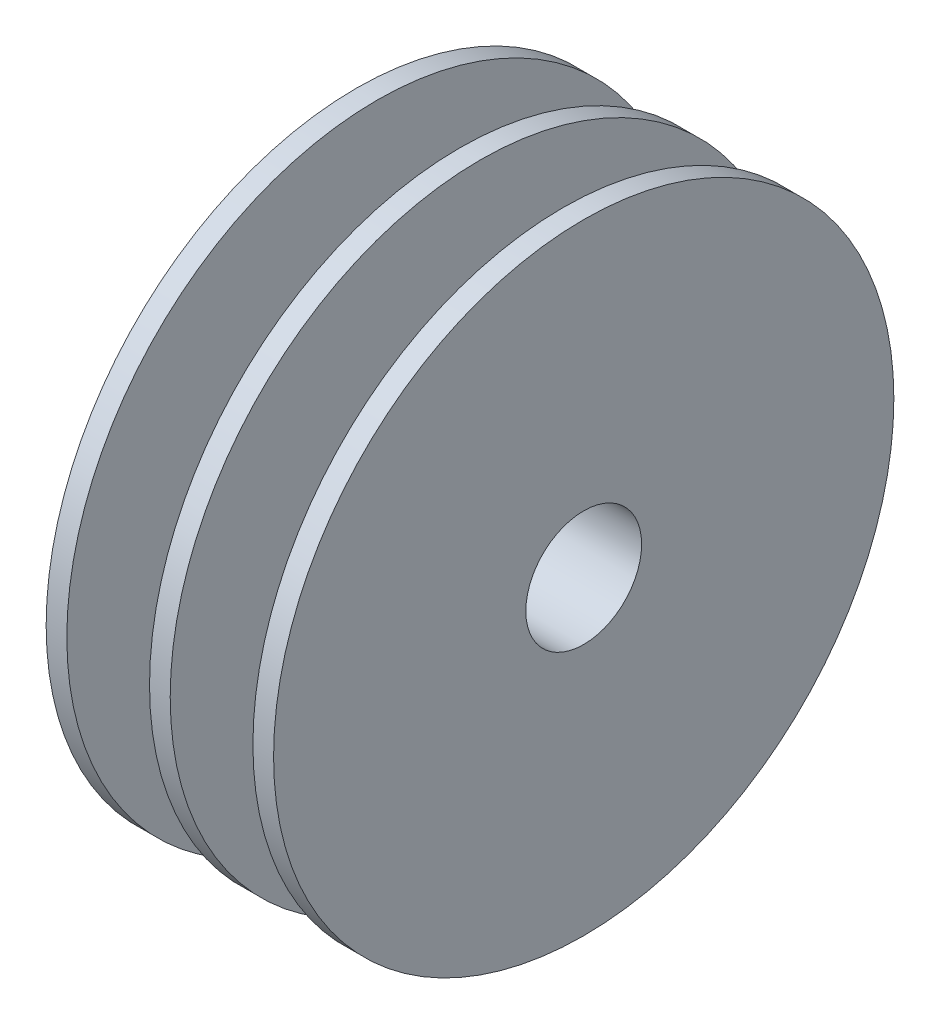
from build123d import *

# Parameters (mm, degrees)
SKETCH2_R           = 15
SKETCH2_R_2         = 5
BOSS_EXTRUDE1_DEPTH = 1
BOSS_EXTRUDE2_START = 1
SKETCH2_3_R         = 5
BOSS_EXTRUDE2_DEPTH = 4
BOSS_EXTRUDE3_START = 5
SKETCH2_5_R         = 15
SKETCH2_5_R_2       = 5
BOSS_EXTRUDE3_DEPTH = 1
BOSS_EXTRUDE4_START = 6
SKETCH2_6_R         = 5
BOSS_EXTRUDE4_DEPTH = 4
BOSS_EXTRUDE5_START = 10
SKETCH2_7_R         = 15
SKETCH2_7_R_2       = 5
BOSS_EXTRUDE5_DEPTH = 1
SKETCH3_R           = 2.375
CUT_EXTRUDE1_DEPTH  = 2
CUT_EXTRUDE6_START  = -3
SKETCH3_4_R         = 2.8
CUT_EXTRUDE6_DEPTH  = 8
SKETCH3_5_R         = 0.6
CUT_EXTRUDE7_DEPTH  = 3


with BuildPart() as part:
    # Sketch2 → Boss-Extrude1 (new body)
    with BuildSketch(Plane(origin=(0, 0, 0), x_dir=(0, 0, -1), z_dir=(1, 0, 0))):
        Circle(SKETCH2_R)
        Circle(SKETCH2_R_2, mode=Mode.SUBTRACT)
        Circle(SKETCH2_R_2)
    extrude(amount=BOSS_EXTRUDE1_DEPTH)

    # Sketch2_3 → Boss-Extrude2 (add)
    with BuildSketch(Plane(origin=(0, 0, 0), x_dir=(0, 0, -1), z_dir=(1, 0, 0)).offset(BOSS_EXTRUDE2_START)):
        Circle(SKETCH2_3_R)
    extrude(amount=BOSS_EXTRUDE2_DEPTH)

    # Sketch2_5 → Boss-Extrude3 (add)
    with BuildSketch(Plane(origin=(0, 0, 0), x_dir=(0, 0, -1), z_dir=(1, 0, 0)).offset(BOSS_EXTRUDE3_START)):
        Circle(SKETCH2_5_R)
        Circle(SKETCH2_5_R_2, mode=Mode.SUBTRACT)
        Circle(SKETCH2_5_R_2)
    extrude(amount=BOSS_EXTRUDE3_DEPTH)

    # Sketch2_6 → Boss-Extrude4 (add)
    with BuildSketch(Plane(origin=(0, 0, 0), x_dir=(0, 0, -1), z_dir=(1, 0, 0)).offset(BOSS_EXTRUDE4_START)):
        Circle(SKETCH2_6_R)
    extrude(amount=BOSS_EXTRUDE4_DEPTH)

    # Sketch2_7 → Boss-Extrude5 (add)
    with BuildSketch(Plane(origin=(0, 0, 0), x_dir=(0, 0, -1), z_dir=(1, 0, 0)).offset(BOSS_EXTRUDE5_START)):
        Circle(SKETCH2_7_R)
        Circle(SKETCH2_7_R_2, mode=Mode.SUBTRACT)
        Circle(SKETCH2_7_R_2)
    extrude(amount=BOSS_EXTRUDE5_DEPTH)

    # Sketch3 → Cut-Extrude1 (cut)
    with BuildSketch(Plane.ZY):
        Circle(SKETCH3_R)
    extrude(amount=-CUT_EXTRUDE1_DEPTH, mode=Mode.SUBTRACT)

    # Sketch3_4 → Cut-Extrude6 (cut)
    with BuildSketch(Plane.ZY.offset(CUT_EXTRUDE6_START)):
        Circle(SKETCH3_4_R)
    extrude(amount=-CUT_EXTRUDE6_DEPTH, mode=Mode.SUBTRACT)

    # Sketch3_5 → Cut-Extrude7 (cut)
    with BuildSketch(Plane.ZY):
        Circle(SKETCH3_5_R)
    extrude(amount=-CUT_EXTRUDE7_DEPTH, mode=Mode.SUBTRACT)


solid = part.part
